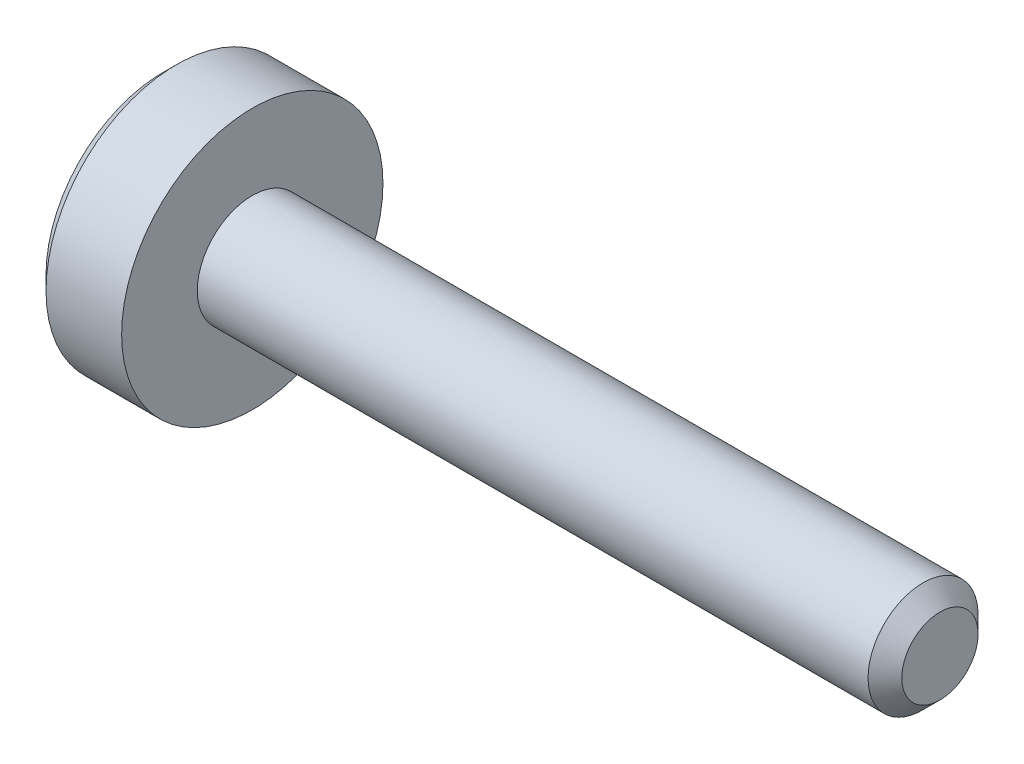
from build123d import *

# Parameters (mm, degrees)
CUT_EXTRUDE1_DEPTH = 0.7


with BuildPart() as part:
    # Sketch1 → Revolve1 (revolve)
    with BuildSketch(Plane.XY):
        Polygon((-1.3, 0), (-1.3, 1.7), (-1.1, 1.9), (0, 1.9), (0, 0.8), (9.7545, 0.8), (10, 0.5545), (10, 0), align=None)
    revolve(axis=Axis((10, 0, 0), (-1, 0, 0)))

    # Sketch2 → Cut-Extrude1 (cut)
    with BuildSketch(Plane(origin=(-1.3, 0, 0), x_dir=(0, 0, -1), z_dir=(1, 0, 0))):
        Polygon((-0.65, -0.375277675), (0, -0.75055535), (0.65, -0.375277675), (0.65, 0.375277675), (0, 0.75055535), (-0.65, 0.375277675), align=None)
    extrude(amount=CUT_EXTRUDE1_DEPTH, mode=Mode.SUBTRACT)


solid = part.part
